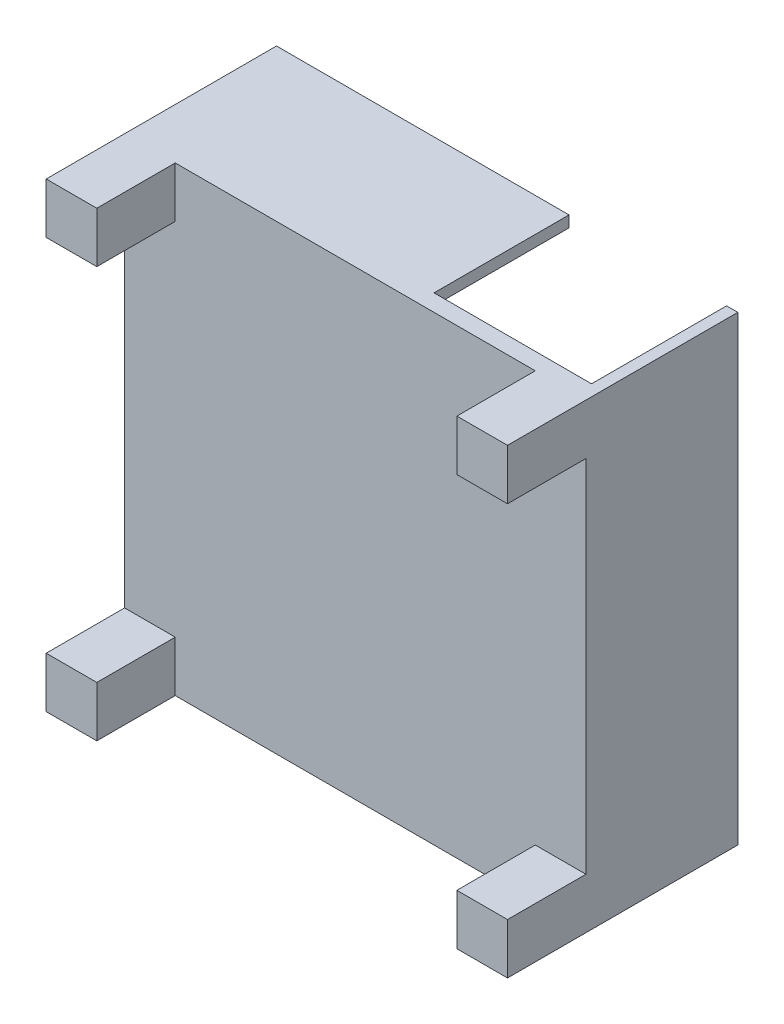
from build123d import *

# Parameters (mm, degrees)
SCHIZZO1_W                   = 41
SCHIZZO1_H                   = 41
ESTRUSIONE_ESTRUSIONE1_DEPTH = 1.5
SCHIZZO5_W                   = 4.5
SCHIZZO5_H                   = 4.5
ESTRUSIONE_ESTRUSIONE2_DEPTH = 6.97
SCHIZZO6_W                   = 4.5
SCHIZZO6_H                   = 4.5
ESTRUSIONE_ESTRUSIONE3_DEPTH = 6.97
SCHIZZO7_W                   = 4.5
SCHIZZO7_H                   = 4.5
ESTRUSIONE_ESTRUSIONE4_DEPTH = 6.97
SCHIZZO8_W                   = 4.5
SCHIZZO8_H                   = 4.5
ESTRUSIONE_ESTRUSIONE5_DEPTH = 6.97
SCHIZZO9_W                   = 1
SCHIZZO9_H                   = 41
ESTRUSIONE_ESTRUSIONE6_DEPTH = 12
SCHIZZO10_W                  = 26
SCHIZZO10_H                  = 1
ESTRUSIONE_ESTRUSIONE7_DEPTH = 12
SCHIZZO11_R                  = 0.4
TAGLIO_ESTRUSIONE1_DEPTH     = 10
SCHIZZO12_R                  = 0.4
TAGLIO_ESTRUSIONE2_DEPTH     = 10


with BuildPart() as part:
    # Schizzo1 → Estrusione-Estrusione1 (new body)
    with BuildSketch(Plane.XY):
        with Locations((20.5, 20.5)):
            Rectangle(SCHIZZO1_W, SCHIZZO1_H)
    extrude(amount=ESTRUSIONE_ESTRUSIONE1_DEPTH)

    # Schizzo5 → Estrusione-Estrusione2 (add)
    with BuildSketch(Plane.XY.offset(1.5)):
        with Locations((2.25, 2.25)):
            Rectangle(SCHIZZO5_W, SCHIZZO5_H)
    extrude(amount=ESTRUSIONE_ESTRUSIONE2_DEPTH)

    # Schizzo6 → Estrusione-Estrusione3 (add)
    with BuildSketch(Plane.XY.offset(1.5)):
        with Locations((38.75, 2.25)):
            Rectangle(SCHIZZO6_W, SCHIZZO6_H)
    extrude(amount=ESTRUSIONE_ESTRUSIONE3_DEPTH)

    # Schizzo7 → Estrusione-Estrusione4 (add)
    with BuildSketch(Plane.XY.offset(1.5)):
        with Locations((2.25, 38.75)):
            Rectangle(SCHIZZO7_W, SCHIZZO7_H)
    extrude(amount=ESTRUSIONE_ESTRUSIONE4_DEPTH)

    # Schizzo8 → Estrusione-Estrusione5 (add)
    with BuildSketch(Plane.XY.offset(1.5)):
        with Locations((38.75, 38.75)):
            Rectangle(SCHIZZO8_W, SCHIZZO8_H)
    extrude(amount=ESTRUSIONE_ESTRUSIONE5_DEPTH)

    # Schizzo9 → Estrusione-Estrusione6 (add)
    with BuildSketch(Plane(origin=(0, 0, 0), x_dir=(-1, 0, 0), z_dir=(0, 0, -1))):
        with Locations((-40.5, 20.5)):
            Rectangle(SCHIZZO9_W, SCHIZZO9_H)
    extrude(amount=ESTRUSIONE_ESTRUSIONE6_DEPTH)

    # Schizzo10 → Estrusione-Estrusione7 (add)
    with BuildSketch(Plane(origin=(0, 0, 0), x_dir=(-1, 0, 0), z_dir=(0, 0, -1))):
        with Locations((-13, 40.5)):
            Rectangle(SCHIZZO10_W, SCHIZZO10_H)
    extrude(amount=ESTRUSIONE_ESTRUSIONE7_DEPTH)

    # Schizzo11 → Taglio-Estrusione1 (cut)
    with BuildSketch(Plane.XY.offset(8.47)):
        with Locations((32.781075858, 214.49933813)):
            Circle(SCHIZZO11_R)
    extrude(amount=-TAGLIO_ESTRUSIONE1_DEPTH, mode=Mode.SUBTRACT)

    # Schizzo12 → Taglio-Estrusione2 (cut)
    with BuildSketch(Plane.XY.offset(8.47)):
        with Locations((-3.518924142, 178.29933813)):
            Circle(SCHIZZO12_R)
    extrude(amount=-TAGLIO_ESTRUSIONE2_DEPTH, mode=Mode.SUBTRACT)


solid = part.part
